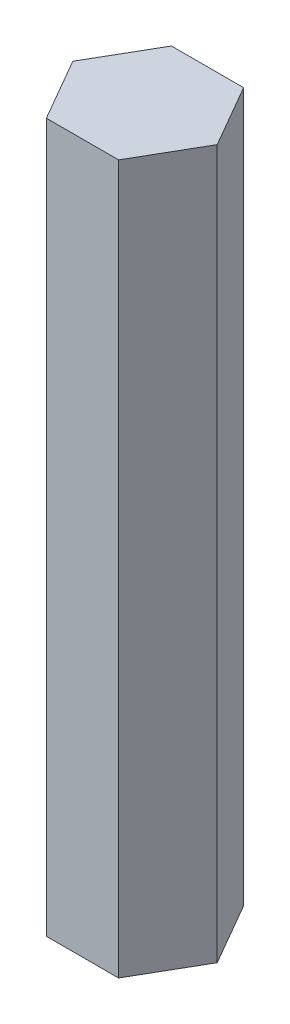
from build123d import *

# Parameters (mm, degrees)
BOSS_EXTRUDE1_DEPTH = 71.9582


with BuildPart() as part:
    # Sketch1 → Boss-Extrude1 (new body)
    with BuildSketch(Plane(origin=(0, 0, 0), x_dir=(1, 0, 0), z_dir=(0, 1, 0))):
        Polygon((7.332348419, 0), (3.666174209, 6.35), (-3.666174209, 6.35), (-7.332348419, 0), (-3.666174209, -6.35), (3.666174209, -6.35), align=None)
    extrude(amount=BOSS_EXTRUDE1_DEPTH)


solid = part.part
